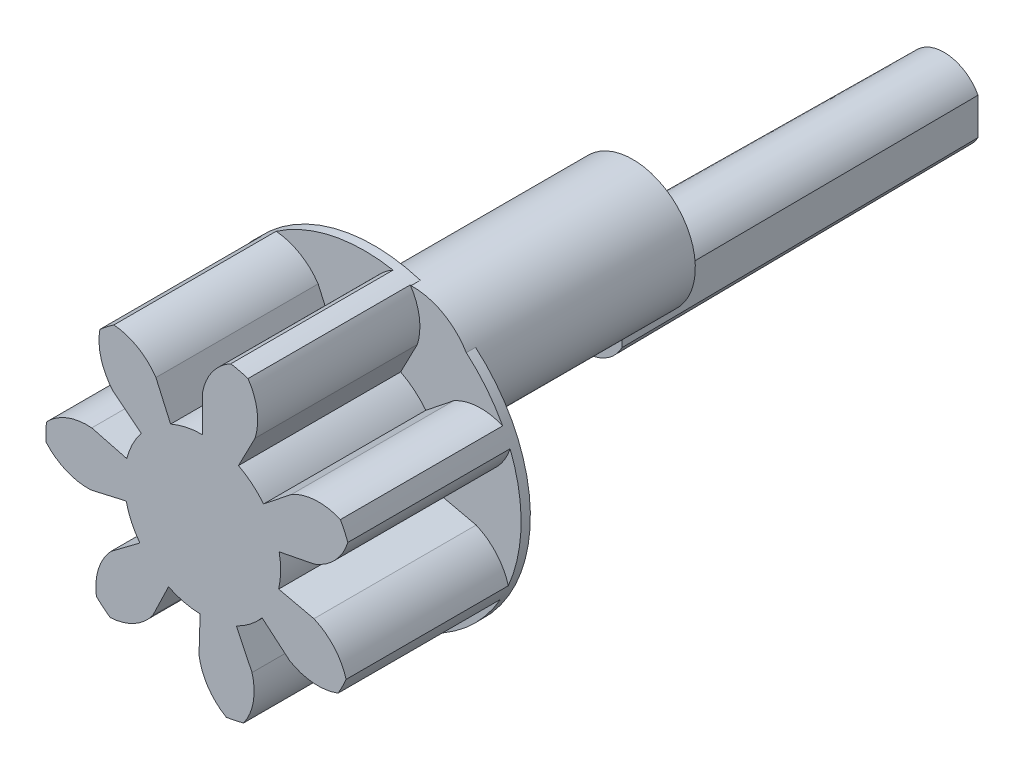
from build123d import *

# Parameters (mm, degrees)
SKETCH2_R                   = 6.75
GEAR_OUTSIDE_DIAMETER_DEPTH = 7
GEAR_TOOTH_CUT_DEPTH        = 8
GEAR_TEETH_COUNT            = 7
SKETCH3_R                   = 3.375
GEAR_DEDENDUM_CIRCLE_DEPTH  = 7
SKETCH8_R                   = 2.7
BOSS_EXTRUDE3_DEPTH         = 9.5
BOSS_EXTRUDE2_DEPTH         = 15.5
BOSS_EXTRUDE2_TAPER         = 0.5
SKETCH9_R                   = 6.75
BOSS_EXTRUDE4_DEPTH         = 0.4


with BuildPart() as part:
    # Sketch2 → gear outside diameter (new body)
    with BuildSketch(Plane.XY):
        Circle(SKETCH2_R)
    extrude(amount=GEAR_OUTSIDE_DIAMETER_DEPTH)

    # Sketch1 → gear tooth cut (cut, through all)
    with BuildSketch(Plane.XY):
        with BuildLine():
            Line((0, 4.933386259), (0, 3.375))
            ThreePointArc((0, 3.375), (-0.701885443, 3.301209146), (-1.373078899, 3.083063304))
            Line((-1.373078899, 3.083063304), (-2.007089948, 4.506649523))
            ThreePointArc((-2.007089948, 4.506649523), (-2.793182164, 5.242332608), (-3.820403893, 5.564801352))
            ThreePointArc((-3.820403893, 5.564801352), (-1.403770885, 6.602418292), (1.225966143, 6.637733575))
            ThreePointArc((1.225966143, 6.637733575), (0.41879145, 5.925245269), (0, 4.933386259))
        make_face()
    gear_tooth_cut = extrude(amount=GEAR_TOOTH_CUT_DEPTH, mode=Mode.SUBTRACT)

    # gear teeth: gear tooth cut ×7 about axis
    gear_teeth_axis = Axis((0, 0, 0), (0, 0, 1))
    for i in range(1, GEAR_TEETH_COUNT):
        add(gear_tooth_cut.rotate(gear_teeth_axis, i * 360 / GEAR_TEETH_COUNT), mode=Mode.SUBTRACT)

    # Sketch3 → gear dedendum circle (add)
    with BuildSketch(Plane.XY):
        Circle(SKETCH3_R)
    extrude(amount=GEAR_DEDENDUM_CIRCLE_DEPTH)

    # Sketch8 → Boss-Extrude3 (add)
    with BuildSketch(Plane(origin=(0, 0, 0), x_dir=(-1, 0, 0), z_dir=(0, 0, -1))):
        with Locations((-2.068006907, 3.746919537)):
            Circle(SKETCH8_R)
    extrude(amount=BOSS_EXTRUDE3_DEPTH)

    # Sketch6 → Boss-Extrude2 (add)
    with BuildSketch(Plane(origin=(0, 0, -9.5), x_dir=(-1, 0, 0), z_dir=(0, 0, -1))):
        with BuildLine():
            ThreePointArc((1.6, 0.824621125), (0, 1.8), (-1.6, 0.824621125))
            Line((-1.6, 0.824621125), (-1.6, -0.824621125))
            ThreePointArc((-1.6, -0.824621125), (0, -1.8), (1.6, -0.824621125))
            Line((1.6, -0.824621125), (1.6, -0.6))
            Line((1.6, -0.6), (1.697056275, -0.6))
            Line((1.697056275, -0.6), (1.697056275, 0.6))
            Line((1.697056275, 0.6), (1.6, 0.6))
            Line((1.6, 0.6), (1.6, 0.824621125))
        make_face()
    extrude(amount=BOSS_EXTRUDE2_DEPTH, taper=BOSS_EXTRUDE2_TAPER)

    # Sketch9 → Boss-Extrude4 (add)
    with BuildSketch(Plane(origin=(0, 0, 0), x_dir=(-1, 0, 0), z_dir=(0, 0, -1))):
        Circle(SKETCH9_R)
    extrude(amount=BOSS_EXTRUDE4_DEPTH)


solid = part.part
